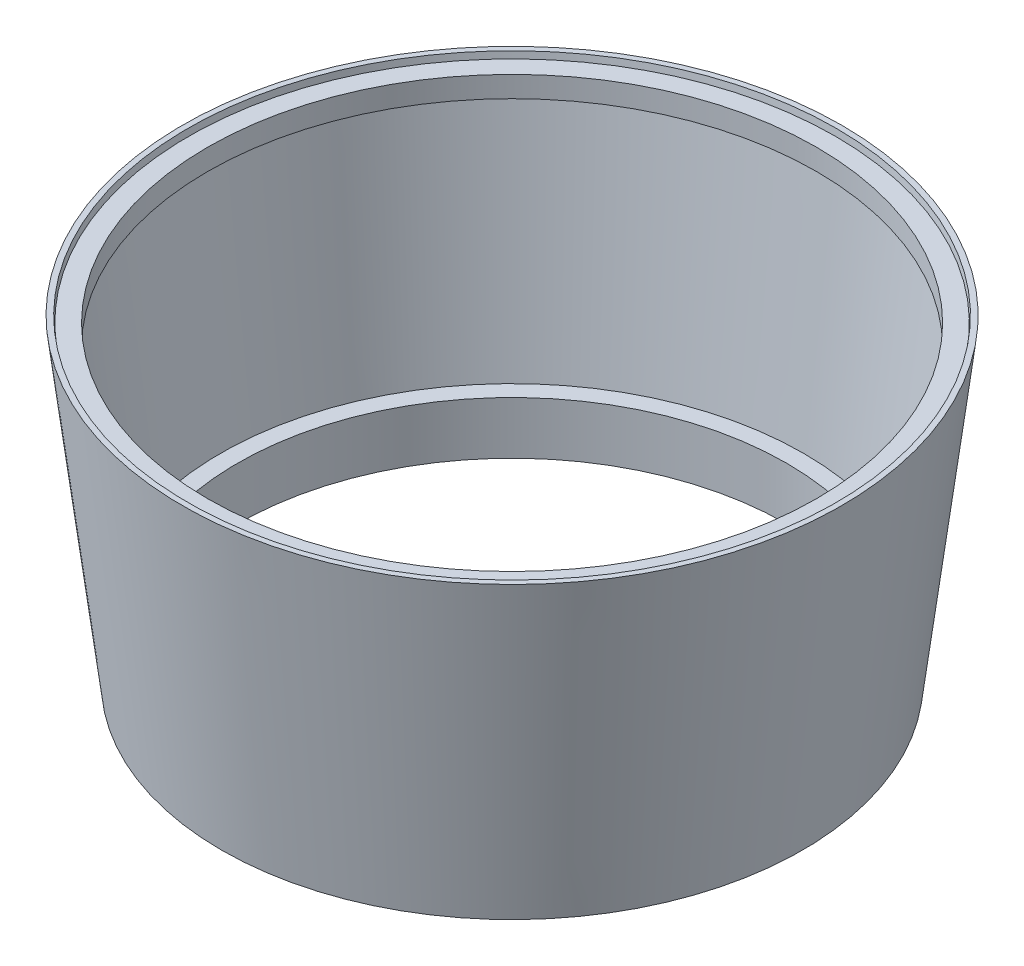
from build123d import *


with BuildPart() as part:
    # 草图1 → 旋转1 (revolve)
    with BuildSketch(Plane.XY):
        Polygon((6.378607461, 4.52446175), (50.555534049, 4.52446175), (158.344356156, 882.393970053), (143.344356156, 882.393970053), (141.136593348, 864.413184913), (88.955118532, 864.413184913), (88.955118532, 806.239804532), (133.993800382, 806.239804532), (53.388370999, 149.761263662), (6.378607461, 149.761263662), align=None)
    revolve(axis=Axis((-752, 4.52446175, 0), (0, 1, 0)))


solid = part.part
